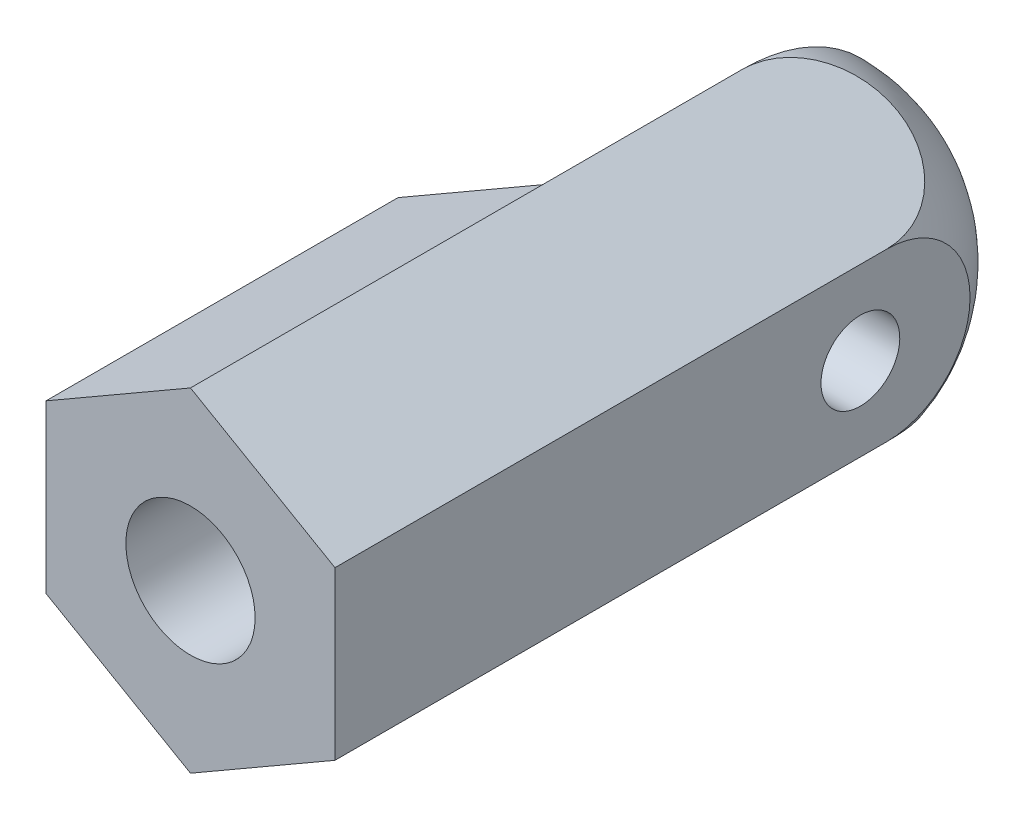
from build123d import *

# Parameters (mm, degrees)
AUFSATZ_LINEAR_AUSTRAGEN1_DEPTH      = 15
SKIZZE1_3_OUTSIDE_W                  = 10.938
SKIZZE1_3_OUTSIDE_H                  = 11.788
SKIZZE1_3_OUTSIDE_R                  = 1.23
SCHNITT_LINEAR_AUSTRAGEN3_DEPTH      = 6
SKIZZE3_R                            = 0.75
SCHNITT_LINEAR_AUSTRAGEN1_DEPTH      = 16.078150509
SCHNITT_LINEAR_AUSTRAGEN2_DEPTH      = 15.306051963
SCHNITT_LINEAR_AUSTRAGEN2_DEPTH_BACK = 15.306051963
SKIZZE4_W                            = 2.75
SKIZZE4_H                            = 6.975426481


with BuildPart() as part:
    # Skizze1 → Aufsatz-Linear austragen1 (new body)
    with BuildSketch(Plane.XY):
        Polygon((-2.75, 1.58771324), (-2.75, -1.58771324), (0, -3.175426481), (2.75, -1.58771324), (2.75, 1.58771324), (0, 3.175426481), align=None)
    extrude(amount=-AUFSATZ_LINEAR_AUSTRAGEN1_DEPTH)

    # Skizze1_3 outside → Schnitt-Linear austragen3 (cut)
    # profile 1 of 2: a face of its own
    with BuildSketch(Plane.XY):
        Rectangle(SKIZZE1_3_OUTSIDE_W, SKIZZE1_3_OUTSIDE_H)
        Polygon((-2.75, 1.58771324), (-2.75, -1.58771324), (0, -3.175426481), (2.75, -1.58771324), (2.75, 1.58771324), (0, 3.175426481), align=None, mode=Mode.SUBTRACT)
    # profile 2 of 2: a face of its own
    with BuildSketch(Plane.XY):
        Circle(SKIZZE1_3_OUTSIDE_R)
    extrude(amount=-SCHNITT_LINEAR_AUSTRAGEN3_DEPTH, mode=Mode.SUBTRACT)

    # Skizze2 → Schnitt-Rotation1 (revolve, cut)
    with BuildSketch(Plane(origin=(0, 0, 0), x_dir=(0, 0, -1), z_dir=(1, 0, 0))):
        with BuildLine():
            Line((10.5, 3.175426481), (10.5, 5))
            Line((10.5, 5), (15, 5))
            Line((15, 5), (15, 0))
            Line((15, 0), (13.675426481, 0))
            ThreePointArc((13.675426481, 0), (12.745365598, 2.245365598), (10.5, 3.175426481))
        make_face()
    revolve(axis=Axis((0, 0, 0), (0, 0, -1)), mode=Mode.SUBTRACT)

    # Skizze3 → Schnitt-Linear austragen1 (cut, through all)
    with BuildSketch(Plane(origin=(2.75, 0, 0), x_dir=(0, 0, -1), z_dir=(1, 0, 0))):
        with Locations((10, 0)):
            Circle(SKIZZE3_R)
    extrude(amount=-SCHNITT_LINEAR_AUSTRAGEN1_DEPTH, mode=Mode.SUBTRACT)

    # Skizze4 → Schnitt-Linear austragen2 (cut, two sides: drawn at the far end of the back side and taken through both)
    with BuildSketch(Plane(origin=(0, 0, 0), x_dir=(1, 0, 0), z_dir=(0, 1, 0)).offset(-SCHNITT_LINEAR_AUSTRAGEN2_DEPTH_BACK)):
        with Locations((-1.375, 10.187713241)):
            Rectangle(SKIZZE4_W, SKIZZE4_H)
    extrude(amount=SCHNITT_LINEAR_AUSTRAGEN2_DEPTH + SCHNITT_LINEAR_AUSTRAGEN2_DEPTH_BACK, mode=Mode.SUBTRACT)


solid = part.part
